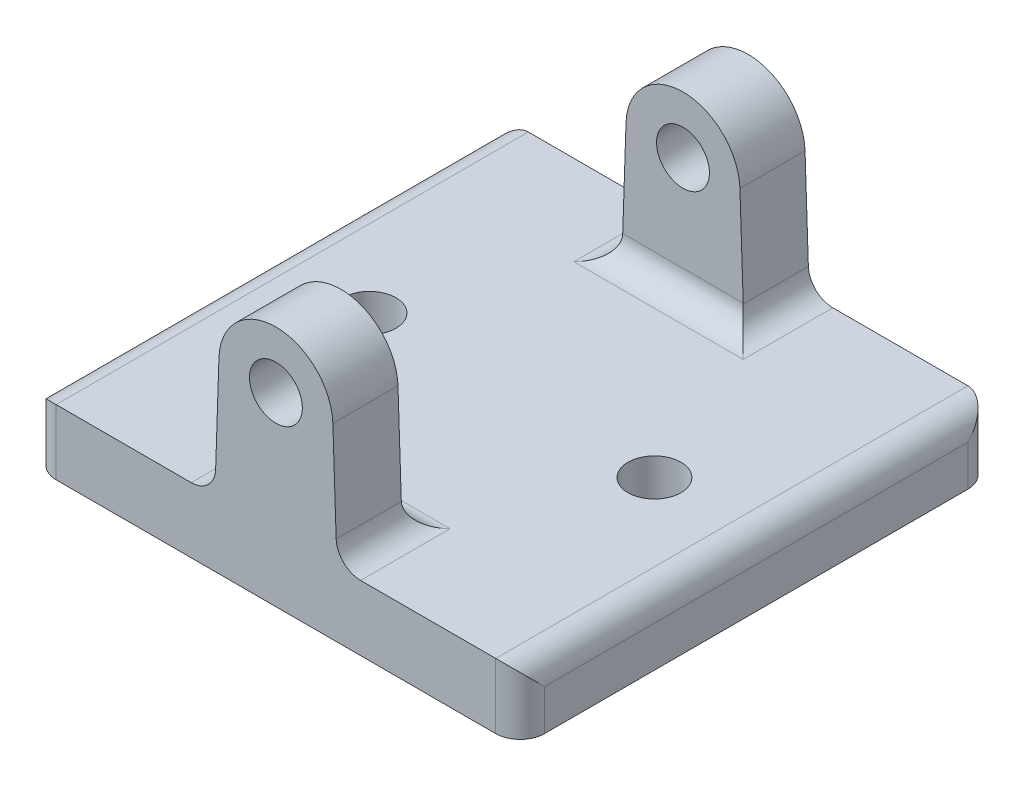
from build123d import *

# Parameters (mm, degrees)
SKETCH2_W           = 60
SKETCH2_H           = 58
SKETCH2_R           = 3.25
BOSS_EXTRUDE1_DEPTH = 8
SKETCH3_R           = 3.25
BOSS_EXTRUDE2_DEPTH = 8
FILLET1_R           = 3


with BuildPart() as part:
    # Sketch2 → Boss-Extrude1 (new body)
    with BuildSketch(Plane(origin=(0, 0, 0), x_dir=(1, 0, 0), z_dir=(0, 1, 0))):
        Rectangle(SKETCH2_W, SKETCH2_H)
        with Locations((-17.5, 0)):
            Circle(SKETCH2_R, mode=Mode.SUBTRACT)
        with Locations((17.5, 0)):
            Circle(SKETCH2_R, mode=Mode.SUBTRACT)
    extrude(amount=BOSS_EXTRUDE1_DEPTH)

    # Sketch3 → Boss-Extrude2 (add)
    with BuildSketch(Plane.XY.offset(29)):
        with BuildLine():
            Line((-7.5, 8), (-6.996052809, 23))
            ThreePointArc((-6.996052809, 23), (0, 29.764957256), (6.996052809, 23))
            Line((6.996052809, 23), (7.5, 8))
            Line((7.5, 8), (-7.5, 8))
        make_face()
        with Locations((0, 22.764957256)):
            Circle(SKETCH3_R, mode=Mode.SUBTRACT)
    boss_extrude2 = extrude(amount=-BOSS_EXTRUDE2_DEPTH)

    # Mirror1: Boss-Extrude2 across plane
    add(boss_extrude2.mirror(Plane.XY))

    # Fillet1
    fillet1_edges = [part.edges().sort_by_distance(p)[0] for p in [
        (-30, 8, 0),
        (0, 8, 21),
        (7.5, 8, 25),
        (-7.5, 8, 25),
        (0, 8, -21),
        (-7.5, 8, -25),
        (7.5, 8, -25),
        (30, 8, 0),
        (30, 4, 29),
        (-30, 4, 29),
        (-30, 4, -29),
        (30, 4, -29),
    ]]
    fillet(fillet1_edges, radius=FILLET1_R)


solid = part.part
